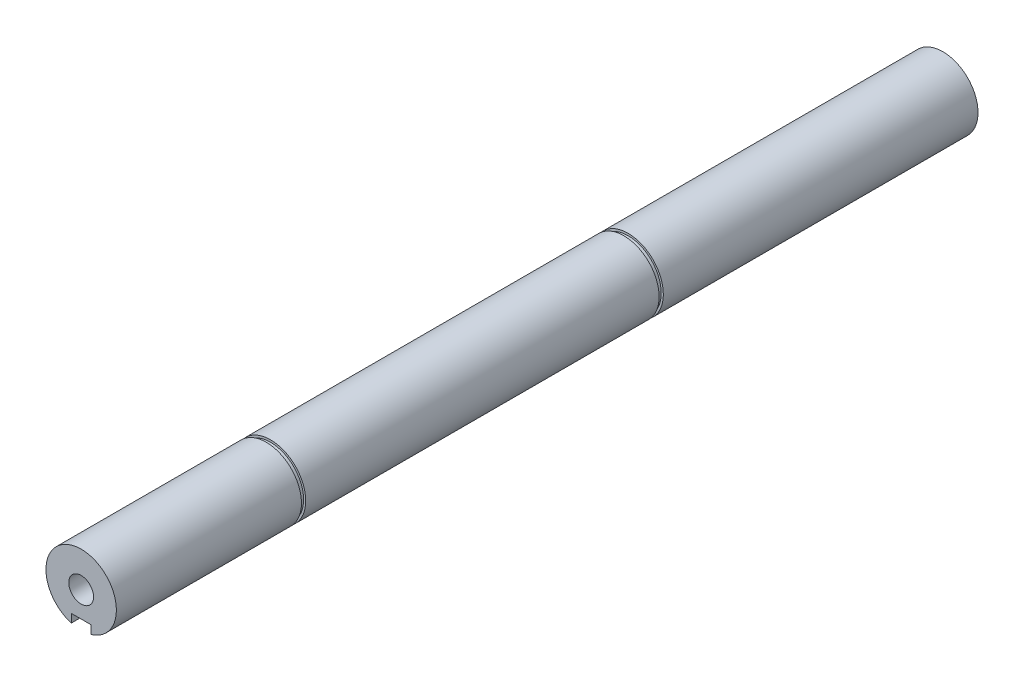
from build123d import *

# Parameters (mm, degrees)
SKETCH_1_R          = 12.5
EXTRUDE_1_DEPTH     = 305.836309
CUT_EXTRUDE_START   = -31.8
SKETCH_2_W          = 7
SKETCH_2_H          = 7
CUT_EXTRUDE_1_DEPTH = 31.8
CUT_EXTRUDE_START_2 = -112
SKETCH_3_W          = 7
SKETCH_3_H          = 7
CUT_EXTRUDE_2_DEPTH = 112
M10X1_251_D         = 8.8
M10X1_251_DEPTH     = 26.25
M10X1_251_TIP       = 2.643786724
M10X1_252_D         = 8.8
M10X1_252_DEPTH     = 26.25
M10X1_252_TIP       = 2.643786724
SKETCH_8_W          = 1.5
SKETCH_8_H          = 0.75


with BuildPart() as part:
    # Эскиз1 → Бобышка-Вытянуть1 (new body)
    with BuildSketch(Plane.XY):
        Circle(SKETCH_1_R)
    extrude(amount=-EXTRUDE_1_DEPTH)

    # Эскиз2 → Вырез-Вытянуть1 (cut)
    with BuildSketch(Plane.XY.offset(CUT_EXTRUDE_START)):
        with Locations((0, -12.5)):
            Rectangle(SKETCH_2_W, SKETCH_2_H)
    extrude(amount=CUT_EXTRUDE_1_DEPTH, mode=Mode.SUBTRACT)

    # Эскиз3 → Вырез-Вытянуть2 (cut)
    with BuildSketch(Plane(origin=(0, 0, -305.836309448), x_dir=(-1, 0, 0), z_dir=(0, 0, -1)).offset(CUT_EXTRUDE_START_2)):
        with Locations((0, -12.5)):
            Rectangle(SKETCH_3_W, SKETCH_3_H)
    extrude(amount=CUT_EXTRUDE_2_DEPTH, mode=Mode.SUBTRACT)

    # Отверстие обработанное метчиком M10x1.251
    with Locations(Plane.XY):
        with Locations((0, 0)):
            Hole(M10X1_251_D / 2, depth=M10X1_251_DEPTH)
            with Locations((0, 0, -(M10X1_251_DEPTH + M10X1_251_TIP / 2))):  # 118° drill point
                Cone(0, M10X1_251_D / 2, M10X1_251_TIP, mode=Mode.SUBTRACT)

    # Отверстие обработанное метчиком M10x1.252
    with Locations(Plane(origin=(0, 0, -305.836309448), x_dir=(-1, 0, 0), z_dir=(0, 0, -1))):
        with Locations((0, 0)):
            Hole(M10X1_252_D / 2, depth=M10X1_252_DEPTH)
            with Locations((0, 0, -(M10X1_252_DEPTH + M10X1_252_TIP / 2))):  # 118° drill point
                Cone(0, M10X1_252_D / 2, M10X1_252_TIP, mode=Mode.SUBTRACT)

    # Эскиз8 → Вырез-Повернуть1 (revolve, cut)
    with BuildSketch(Plane(origin=(0, 0, 0), x_dir=(0, 0, -1), z_dir=(1, 0, 0))):
        with Locations((66.45, 12.125)):
            Rectangle(SKETCH_8_W, SKETCH_8_H)
        with Locations((193.386309448, 12.125)):
            Rectangle(SKETCH_8_W, SKETCH_8_H)
    revolve(axis=Axis((0, 0, 1000), (0, 0, -1)), mode=Mode.SUBTRACT)


solid = part.part
